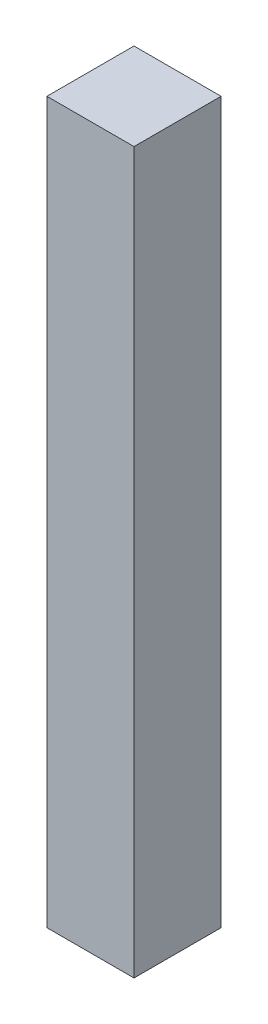
from build123d import *

# Parameters (mm, degrees)
SKETCH1_W           = 25.4
SKETCH1_H           = 25.4
BOSS_EXTRUDE1_DEPTH = 210


with BuildPart() as part:
    # Sketch1 → Boss-Extrude1 (new body)
    with BuildSketch(Plane(origin=(0, 0, 0), x_dir=(1, 0, 0), z_dir=(0, 1, 0))):
        with Locations((-27.135508984, 5.913615805)):
            Rectangle(SKETCH1_W, SKETCH1_H)
    extrude(amount=BOSS_EXTRUDE1_DEPTH)


solid = part.part
